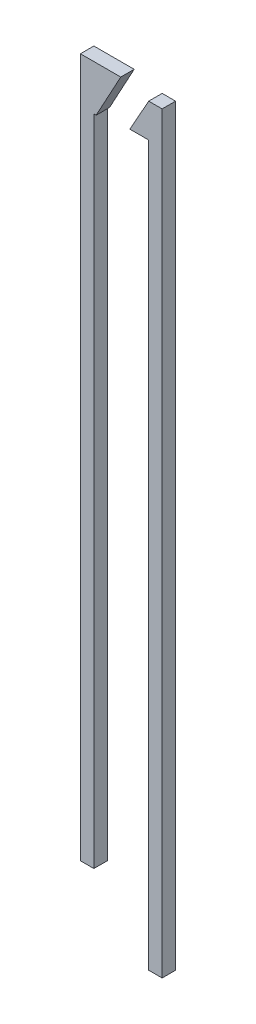
from build123d import *

# Parameters (mm, degrees)
BOSS_EXTRUDE1_DEPTH   = 0.5
BOSS_EXTRUDE1_2_DEPTH = 0.5


with BuildPart() as part:
    # Sketch1 → Boss-Extrude1 (new body)
    with BuildSketch(Plane.XY):
        Polygon((2.391735862, 12.78255814), (2.891735862, 12.78255814), (2.891735862, -15.21744186), (2.391735862, -15.21744186), (2.391735862, 11.528764229), (1.691735862, 11.528764229), align=None)
    extrude(amount=BOSS_EXTRUDE1_DEPTH)


with BuildPart() as body_2:
    # Sketch1 → Boss-Extrude1 2 (new body)
    with BuildSketch(Plane.XY):
        Polygon((-0.148264138, 13.038708658), (1.351735862, 13.038708658), (0.435111642, 11.35), (0.351735862, 11.35), (0.351735862, -12.961291342), (-0.148264138, -12.961291342), align=None)
    extrude(amount=BOSS_EXTRUDE1_2_DEPTH)


solid = Compound([part.part, body_2.part])
